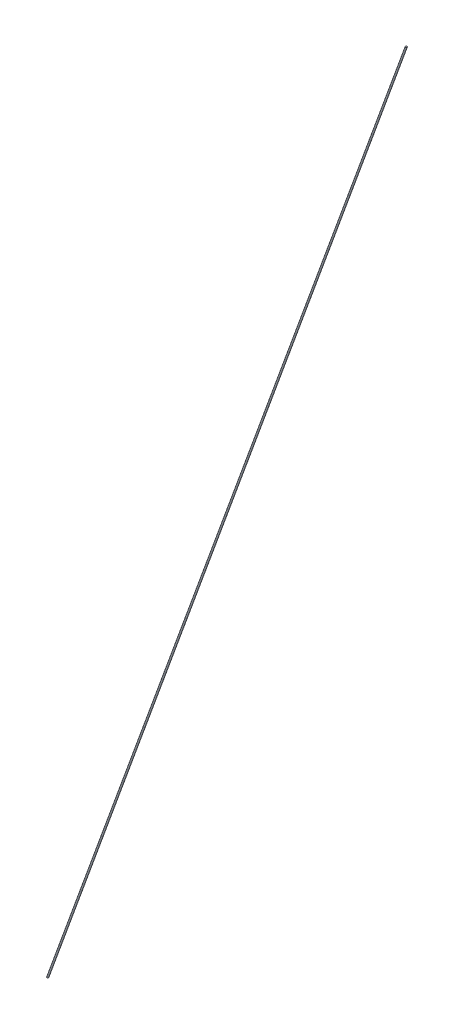
from build123d import *


with BuildPart() as part:
    # Sketch1 → Revolve1 (revolve)
    with BuildSketch(Plane.XY):
        Polygon((54.371065375, 298.378202546), (-30.904947918, 64.0842816), (-30.704947918, 64.0842816), (54.571065375, 298.378202546), align=None)
    revolve(axis=Axis((-30.704947918, 64.0842816, 0), (0.342020143, 0.939692621, 0)))


solid = part.part
